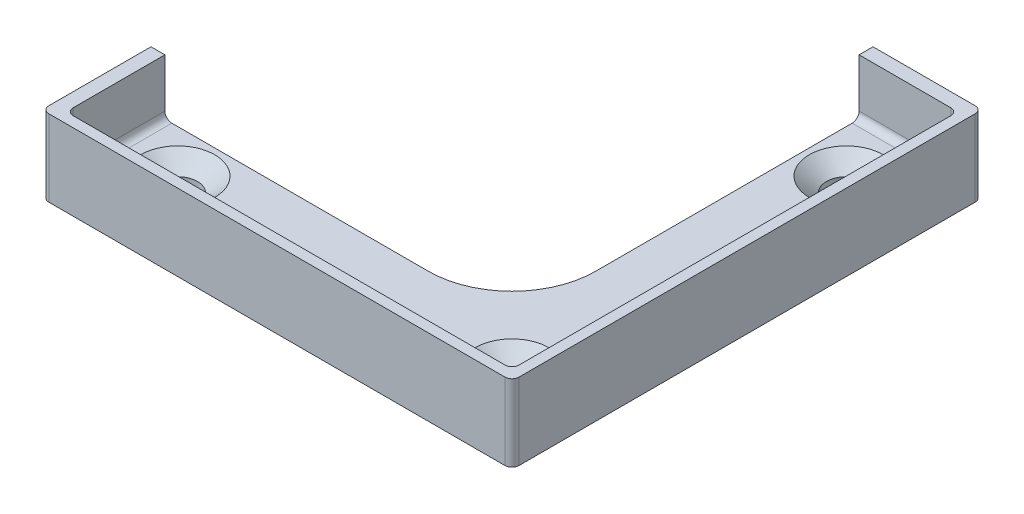
from build123d import *

# Parameters (mm, degrees)
SKETCH1_W                                         = 53.975
SKETCH1_H                                         = 53.975
SKETCH1_W_2                                       = 50.8
SKETCH1_H_2                                       = 50.8
BOSS_EXTRUDE1_DEPTH                               = 6.35
SKETCH2_W                                         = 53.975
SKETCH2_H                                         = 53.975
BOSS_EXTRUDE2_DEPTH                               = 2.38125
BOSS_EXTRUDE3_DEPTH                               = 3.2512
BOSS_EXTRUDE3_DEPTH_BACK                          = 1.5875
CSK_FOR_8_FLAT_HEAD_MACHINE_SCREW_100_D           = 4.4958
CSK_FOR_8_FLAT_HEAD_MACHINE_SCREW_100_CSINK_D     = 8.4328
CSK_FOR_8_FLAT_HEAD_MACHINE_SCREW_100_CSINK_ANGLE = 100
SKETCH7_W                                         = 41.148
SKETCH7_H                                         = 41.148
CUT_EXTRUDE1_DEPTH                                = 7.35
CUT_EXTRUDE1_DEPTH_BACK                           = 6.63245
FILLET2_R                                         = 9.525
BOSS_EXTRUDE4_DEPTH                               = 7.14375
CUT_EXTRUDE2_DEPTH                                = 12.98245
FILLET3_R                                         = 0.79375


with BuildPart() as part:
    # Sketch1 → Boss-Extrude1 (new body)
    with BuildSketch(Plane(origin=(0, 0, 0), x_dir=(1, 0, 0), z_dir=(0, 1, 0))):
        Rectangle(SKETCH1_W, SKETCH1_H)
        Rectangle(SKETCH1_W_2, SKETCH1_H_2, mode=Mode.SUBTRACT)
    extrude(amount=BOSS_EXTRUDE1_DEPTH)

    # Sketch2 → Boss-Extrude2 (add)
    with BuildSketch(Plane.XZ):
        Rectangle(SKETCH2_W, SKETCH2_H)
    extrude(amount=BOSS_EXTRUDE2_DEPTH)

    # Sketch3 → Boss-Extrude3 (add, two sides)
    with BuildSketch(Plane.XZ.offset(2.38125)) as boss_extrude3_sk:
        Polygon((-26.9875, 26.590625), (26.590625, 26.590625), (26.590625, -26.9875), (28.178125, -26.9875), (28.178125, 28.178125), (-26.9875, 28.178125), align=None)
    extrude(amount=BOSS_EXTRUDE3_DEPTH)
    extrude(boss_extrude3_sk.sketch, amount=-BOSS_EXTRUDE3_DEPTH_BACK)

    # CSK for #8 Flat Head Machine Screw (100)1 (through all)
    with Locations(Plane(origin=(19.05, 0, 19.05), x_dir=(0, 0, 1), z_dir=(0, 1, 0))):
        with Locations((0, 0), (-38.1, -38.1), (-38.1, 0), (0, -38.1)):
            CounterSinkHole(CSK_FOR_8_FLAT_HEAD_MACHINE_SCREW_100_D / 2, CSK_FOR_8_FLAT_HEAD_MACHINE_SCREW_100_CSINK_D / 2, counter_sink_angle=CSK_FOR_8_FLAT_HEAD_MACHINE_SCREW_100_CSINK_ANGLE)

    # Sketch7 → Cut-Extrude1 (cut, two sides)
    with BuildSketch(Plane(origin=(0, 0, 0), x_dir=(1, 0, 0), z_dir=(0, 1, 0))) as cut_extrude1_sk:
        with Locations((-6.4135, 6.4135)):
            Rectangle(SKETCH7_W, SKETCH7_H)
    extrude(amount=CUT_EXTRUDE1_DEPTH, mode=Mode.SUBTRACT)
    extrude(cut_extrude1_sk.sketch, amount=-CUT_EXTRUDE1_DEPTH_BACK, mode=Mode.SUBTRACT)

    # Fillet2
    fillet2_edges = [part.edges().sort_by_distance(p)[0] for p in [
        (14.1605, -1.190625, 14.1605),
    ]]
    fillet(fillet2_edges, radius=FILLET2_R)

    # Sketch8 → Boss-Extrude4 (add)
    with BuildSketch(Plane(origin=(0, -0.79375, 0), x_dir=(1, 0, 0), z_dir=(0, 1, 0))):
        Polygon((28.178125, 26.9875), (26.9875, 26.9875), (26.9875, -26.9875), (-26.9875, -26.9875), (-26.9875, -28.178125), (28.178125, -28.178125), align=None)
    extrude(amount=BOSS_EXTRUDE4_DEPTH)

    # Sketch9 → Cut-Extrude2 (cut, through all)
    with BuildSketch(Plane.XZ.offset(5.63245)):
        Polygon((-26.9875, 28.178125), (-26.9875, 26.590625), (26.590625, 26.590625), (26.590625, -26.9875), (28.178125, -26.9875), (28.178125, 28.178125), align=None)
    extrude(amount=-CUT_EXTRUDE2_DEPTH, mode=Mode.SUBTRACT)

    # Fillet3
    fillet3_edges = [part.edges().sort_by_distance(p)[0] for p in [
        (26.590625, 1.984375, -26.9875),
        (26.590625, 1.984375, 26.590625),
        (-26.9875, 1.984375, 26.590625),
        (25.4, 0, 0),
        (25.4, 3.175, 25.4),
        (19.78025, 0, -25.4),
        (25.4, 3.175, -25.4),
        (0, 0, 25.4),
        (-25.4, 3.175, 25.4),
        (-25.4, 0, 19.78025),
    ]]
    fillet(fillet3_edges, radius=FILLET3_R)


solid = part.part
